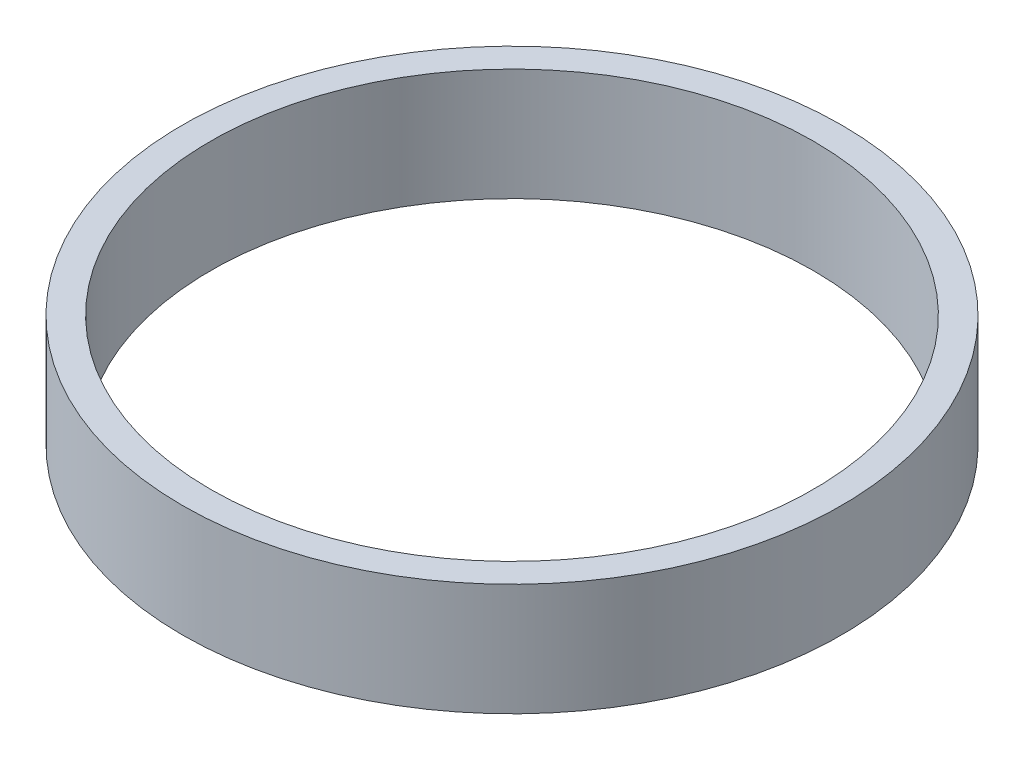
from build123d import *

# Parameters (mm, degrees)
SKETCH1_R           = 1193.8
SKETCH1_R_2         = 1092.2
BOSS_EXTRUDE1_DEPTH = 203.2


with BuildPart() as part:
    # Sketch1 → Boss-Extrude1 (new body, symmetric)
    with BuildSketch(Plane(origin=(0, 0, 0), x_dir=(1, 0, 0), z_dir=(0, 1, 0))):
        Circle(SKETCH1_R)
        Circle(SKETCH1_R_2, mode=Mode.SUBTRACT)
    extrude(amount=BOSS_EXTRUDE1_DEPTH, both=True)


solid = part.part
